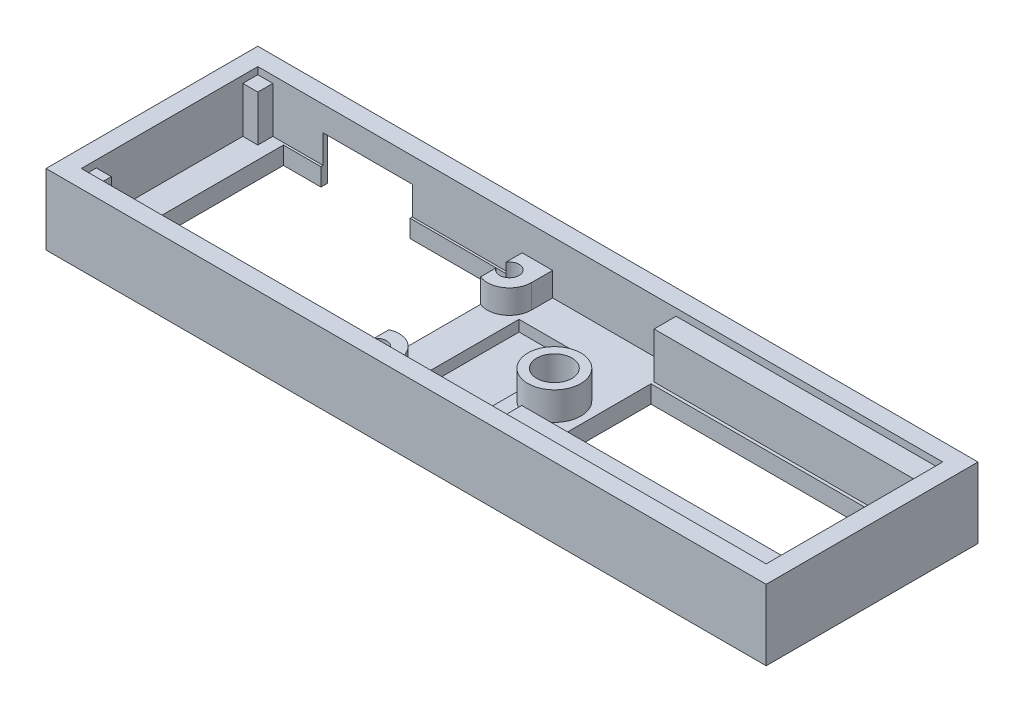
from build123d import *

# Parameters (mm, degrees)
SKETCH2_W           = 81.6
SKETCH2_H           = 24
SKETCH2_W_2         = 77.6
SKETCH2_H_2         = 20
BOSS_EXTRUDE1_DEPTH = 8
SKETCH3_W           = 77.6
SKETCH3_H           = 20
BOSS_EXTRUDE2_DEPTH = 2
SKETCH4_R           = 2
SKETCH4_W           = 26.8
SKETCH4_H           = 19.5
SKETCH4_W_2         = 30.2
SKETCH4_H_2         = 14.3
CUT_EXTRUDE1_DEPTH  = 9
SKETCH6_W           = 30.2
SKETCH6_H           = 2.5
SKETCH6_W_2         = 1.7
SKETCH6_H_2         = 1.7
BOSS_EXTRUDE5_DEPTH = 5.2
SKETCH11_R          = 3
SKETCH11_R_2        = 2
BOSS_EXTRUDE6_DEPTH = 3.2
BOSS_EXTRUDE7_DEPTH = 2.7
SKETCH13_R          = 1.1
CUT_EXTRUDE2_DEPTH  = 4
CUT_EXTRUDE3_REACH  = 26
SKETCH15_W          = 10.1
SKETCH15_H          = 5.2
CHAMFER1_SIZE       = 1.5
SKETCH16_W          = 7
SKETCH16_H          = 12
CUT_EXTRUDE4_DEPTH  = 1.25


with BuildPart() as part:
    # Sketch2 → Boss-Extrude1 (new body)
    with BuildSketch(Plane(origin=(0, 0, 0), x_dir=(1, 0, 0), z_dir=(0, 1, 0))):
        Rectangle(SKETCH2_W, SKETCH2_H)
        Rectangle(SKETCH2_W_2, SKETCH2_H_2, mode=Mode.SUBTRACT)
    extrude(amount=BOSS_EXTRUDE1_DEPTH)

    # Sketch3 → Boss-Extrude2 (add)
    with BuildSketch(Plane(origin=(0, 0, 0), x_dir=(1, 0, 0), z_dir=(0, 1, 0))):
        Rectangle(SKETCH3_W, SKETCH3_H)
    extrude(amount=BOSS_EXTRUDE2_DEPTH)

    # Sketch4 → Cut-Extrude1 (cut, through all)
    with BuildSketch(Plane(origin=(0, 8, 0), x_dir=(1, 0, 0), z_dir=(0, 1, 0))):
        with Locations((4.8, 0)):
            Circle(SKETCH4_R)
        with Locations((-22.25, 0)):
            Rectangle(SKETCH4_W, SKETCH4_H)
        with Locations((23.7, 0)):
            Rectangle(SKETCH4_W_2, SKETCH4_H_2)
    extrude(amount=-CUT_EXTRUDE1_DEPTH, mode=Mode.SUBTRACT)

    # Sketch6 → Boss-Extrude5 (add)
    with BuildSketch(Plane(origin=(0, 2, 0), x_dir=(-1, 0, 0), z_dir=(0, 1, 0))):
        with Locations((-23.7, 8.75)):
            Rectangle(SKETCH6_W, SKETCH6_H)
        with Locations((-23.7, -8.75)):
            Rectangle(SKETCH6_W, SKETCH6_H)
        with Locations((37.95, 9.15)):
            Rectangle(SKETCH6_W_2, SKETCH6_H_2)
        with Locations((37.95, -9.15)):
            Rectangle(SKETCH6_W_2, SKETCH6_H_2)
    extrude(amount=BOSS_EXTRUDE5_DEPTH)

    # Sketch11 → Boss-Extrude6 (add)
    with BuildSketch(Plane(origin=(0, 2, 0), x_dir=(1, 0, 0), z_dir=(0, 1, 0))):
        with Locations((4.8, 0)):
            Circle(SKETCH11_R)
        with Locations((4.8, 0)):
            Circle(SKETCH11_R_2, mode=Mode.SUBTRACT)
    extrude(amount=BOSS_EXTRUDE6_DEPTH)

    # Sketch8 → Boss-Extrude7 (add)
    with BuildSketch(Plane(origin=(0, 2, 0), x_dir=(1, 0, 0), z_dir=(0, 1, 0))):
        with BuildLine():
            Line((-8.85, -9.75), (-8.85, -5.087533784))
            ThreePointArc((-8.85, -5.087533784), (-6.508058909, -5.323344034), (-5.4, -7.4))
            Line((-5.4, -7.4), (-5.4, -10))
            Line((-5.4, -10), (-8.85, -10))
            Line((-8.85, -10), (-8.85, -9.75))
        make_face()
        with BuildLine():
            Line((-5.4, 10), (-8.85, 10))
            Line((-8.85, 10), (-8.85, 9.75))
            Line((-8.85, 9.75), (-8.85, 5.287533784))
            ThreePointArc((-8.85, 5.287533784), (-6.508058909, 5.523344034), (-5.4, 7.6))
            Line((-5.4, 7.6), (-5.4, 10))
        make_face()
    extrude(amount=BOSS_EXTRUDE7_DEPTH)

    # Sketch13 → Cut-Extrude2 (cut)
    with BuildSketch(Plane(origin=(0, 4.7, 0), x_dir=(1, 0, 0), z_dir=(0, 1, 0))):
        with Locations((-7.9, 7.6)):
            Circle(SKETCH13_R)
        with Locations((-7.9, -7.4)):
            Circle(SKETCH13_R)
    extrude(amount=-CUT_EXTRUDE2_DEPTH, mode=Mode.SUBTRACT)

    # Sketch15 → Cut-Extrude3 (cut, up to next)
    with BuildSketch(Plane(origin=(0, 0, -12), x_dir=(-1, 0, 0), z_dir=(0, 0, -1)), mode=Mode.PRIVATE) as cut_extrude3_sk1:
        with Locations((26.35, 2.6)):
            Rectangle(SKETCH15_W, SKETCH15_H)
    cut_extrude3_tool1 = extrude(cut_extrude3_sk1.sketch, amount=-CUT_EXTRUDE3_REACH, mode=Mode.PRIVATE) & part.part
    add(cut_extrude3_tool1.solids().sort_by_distance((-26.35, 2.6, -12))[0], mode=Mode.SUBTRACT)

    # Chamfer1
    chamfer1_edges = [part.edges().sort_by_distance(p)[0] for p in [
        (-21.3, 2.6, -12),
        (-31.4, 2.6, -12),
        (-26.35, 5.2, -12),
    ]]
    chamfer(chamfer1_edges, length=CHAMFER1_SIZE)

    # Sketch16 → Cut-Extrude4 (cut)
    with BuildSketch(Plane(origin=(0, 2, 0), x_dir=(1, 0, 0), z_dir=(0, 1, 0))):
        with Locations((-1.7, 0)):
            Rectangle(SKETCH16_W, SKETCH16_H)
    extrude(amount=-CUT_EXTRUDE4_DEPTH, mode=Mode.SUBTRACT)


solid = part.part
